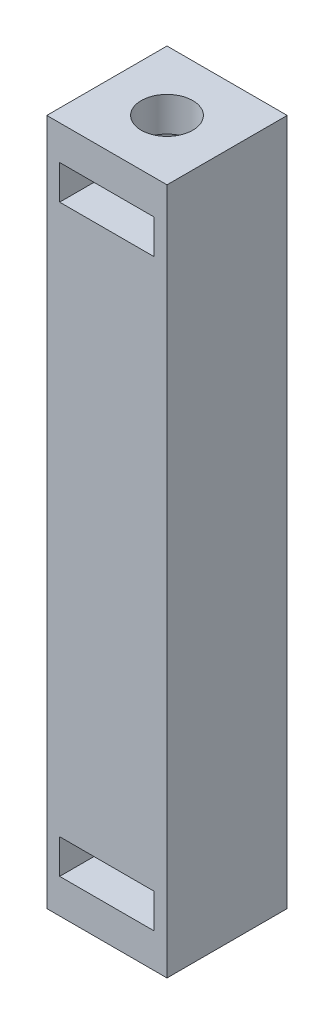
from build123d import *

# Parameters (mm, degrees)
SKETCH1_W           = 7
SKETCH1_H           = 7
BOSS_EXTRUDE1_DEPTH = 40
SKETCH2_R           = 1.5
CUT_EXTRUDE1_DEPTH  = 41
SKETCH3_W           = 5.5
SKETCH3_H           = 2
CUT_EXTRUDE2_DEPTH  = 41


with BuildPart() as part:
    # Sketch1 → Boss-Extrude1 (new body)
    with BuildSketch(Plane(origin=(0, 0, 0), x_dir=(1, 0, 0), z_dir=(0, 1, 0))):
        Rectangle(SKETCH1_W, SKETCH1_H)
    extrude(amount=BOSS_EXTRUDE1_DEPTH)

    # Sketch2 → Cut-Extrude1 (cut)
    with BuildSketch(Plane(origin=(0, 40, 0), x_dir=(1, 0, 0), z_dir=(0, 1, 0))):
        Circle(SKETCH2_R)
    extrude(amount=-CUT_EXTRUDE1_DEPTH, mode=Mode.SUBTRACT)

    # Sketch3 → Cut-Extrude2 (cut)
    with BuildSketch(Plane.XY.offset(3.5)):
        with Locations((0, 3)):
            Rectangle(SKETCH3_W, SKETCH3_H)
        with Locations((0, 37)):
            Rectangle(SKETCH3_W, SKETCH3_H)
    extrude(amount=-CUT_EXTRUDE2_DEPTH, mode=Mode.SUBTRACT)


solid = part.part
